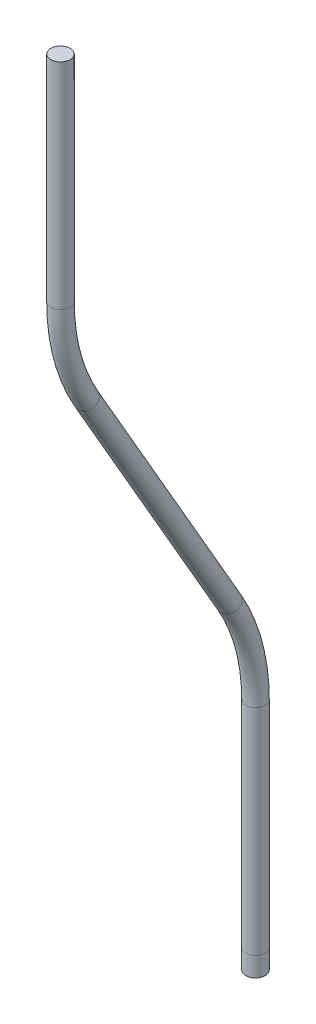
from build123d import *

# Parameters (mm, degrees)
SWEEP1_PROFILE_R = 1


with BuildPart() as part:
    # Sweep1: sweep along a path in Sketch2
    with BuildLine(Plane(origin=(0, 0, 0), x_dir=(0, 0, -1), z_dir=(1, 0, 0))) as sweep1_path:
        Line((-20, 91.358983849), (-20, 69.358983849))
        ThreePointArc((-20, 69.358983849), (-19.318516526, 64.182602947), (-17.320508076, 59.358983849))
        Line((-17.320508076, 59.358983849), (-2.679491924, 34))
        ThreePointArc((-2.679491924, 34), (-0.681483474, 29.176380902), (0, 24))
        Line((0, 24), (0, 2))
        Line((0, 2), (0, 0))
    # Sweep1 profile (on start of the path) → Sweep1 (sweep)
    with BuildSketch(Plane(origin=(0, 91.358983849, 20), x_dir=(0, 0, -1), z_dir=(0, -1, 0))):
        Circle(SWEEP1_PROFILE_R)
    sweep(path=sweep1_path.line)


solid = part.part
